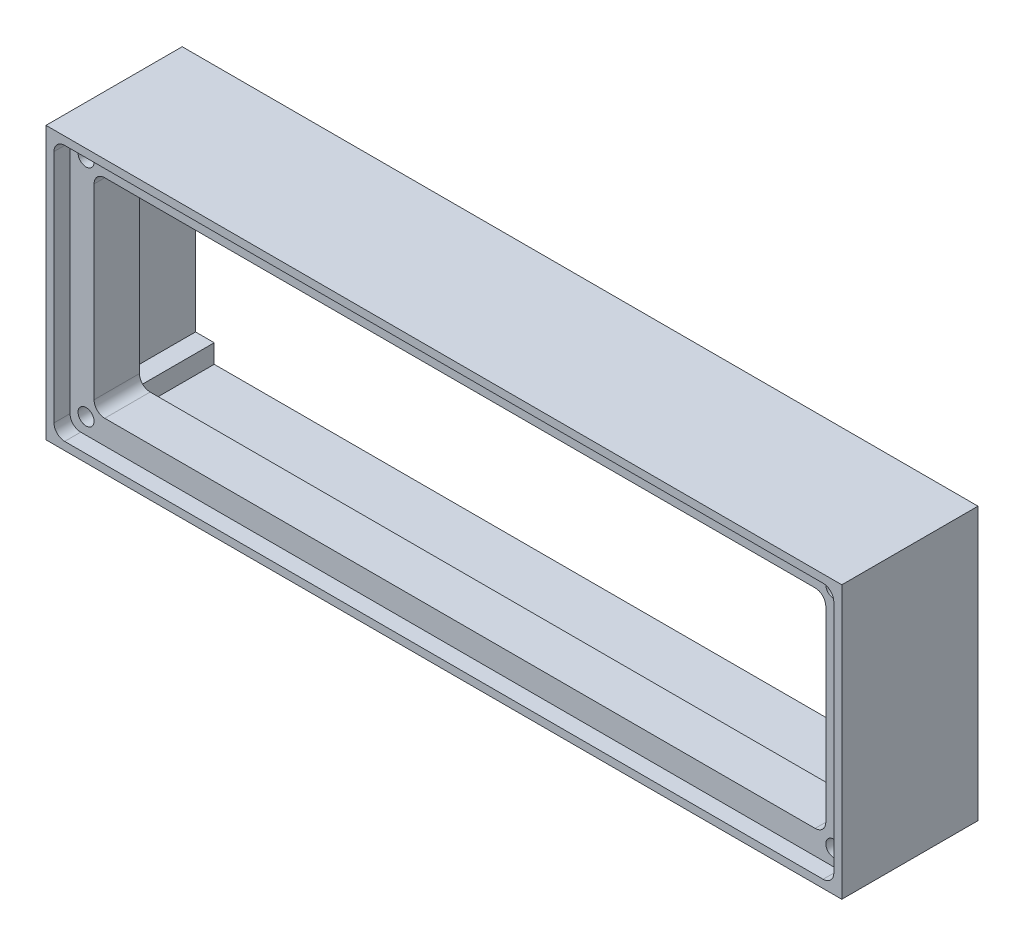
from build123d import *

# Parameters (mm, degrees)
SKETCH1_W           = 149
SKETCH1_H           = 51
SKETCH1_W_2         = 137
SKETCH1_H_2         = 39
EXTRUDE_THIN1_DEPTH = 25.5
SKETCH2_W           = 146
SKETCH2_H           = 48
CUT_EXTRUDE1_DEPTH  = 3
CUT_EXTRUDE2_DEPTH  = 8
CUT_EXTRUDE3_DEPTH  = 8
FILLET1_R           = 2
FILLET2_R           = 2
CUT_EXTRUDE7_DEPTH  = 14


with BuildPart() as part:
    # Sketch1 → Extrude-Thin1 (new body)
    with BuildSketch(Plane.XY):
        with Locations((74.5, 25.5)):
            Rectangle(SKETCH1_W, SKETCH1_H)
        with Locations((74.5, 25.5)):
            Rectangle(SKETCH1_W_2, SKETCH1_H_2, mode=Mode.SUBTRACT)
    extrude(amount=EXTRUDE_THIN1_DEPTH)

    # Sketch2 → Cut-Extrude1 (cut)
    with BuildSketch(Plane.XY.offset(25.5)):
        with Locations((74.5, 25.5)):
            Rectangle(SKETCH2_W, SKETCH2_H)
    extrude(amount=-CUT_EXTRUDE1_DEPTH, mode=Mode.SUBTRACT)

    # Sketch3 → Cut-Extrude2 (cut)
    with BuildSketch(Plane.XY.offset(22.5)):
        with BuildLine():
            ThreePointArc((4.5, 45), (5.560660172, 45.439339828), (6, 46.5))
            Line((6, 46.5), (4.5, 46.5))
            Line((4.5, 46.5), (4.5, 45))
        make_face()
        with BuildLine():
            Line((4.5, 46.5), (6, 46.5))
            ThreePointArc((6, 46.5), (3.439339828, 47.560660172), (4.5, 45))
            Line((4.5, 45), (4.5, 46.5))
        make_face()
        with BuildLine():
            ThreePointArc((4.5, 45), (5.560660172, 45.439339828), (6, 46.5))
            Line((6, 46.5), (4.5, 46.5))
            Line((4.5, 46.5), (4.5, 45))
        make_face()
        with BuildLine():
            Line((4.5, 46.5), (6, 46.5))
            ThreePointArc((6, 46.5), (3.439339828, 47.560660172), (4.5, 45))
            Line((4.5, 45), (4.5, 46.5))
        make_face()
        with BuildLine():
            ThreePointArc((6, 4.5), (5.560660172, 5.560660172), (4.5, 6))
            Line((4.5, 6), (4.5, 4.5))
            Line((4.5, 4.5), (6, 4.5))
        make_face()
        with BuildLine():
            Line((4.5, 4.5), (4.5, 6))
            ThreePointArc((4.5, 6), (3.439339828, 3.439339828), (6, 4.5))
            Line((6, 4.5), (4.5, 4.5))
        make_face()
        with BuildLine():
            ThreePointArc((6, 4.5), (5.560660172, 5.560660172), (4.5, 6))
            Line((4.5, 6), (4.5, 4.5))
            Line((4.5, 4.5), (6, 4.5))
        make_face()
        with BuildLine():
            Line((4.5, 4.5), (4.5, 6))
            ThreePointArc((4.5, 6), (3.439339828, 3.439339828), (6, 4.5))
            Line((6, 4.5), (4.5, 4.5))
        make_face()
        with BuildLine():
            ThreePointArc((146, 46.5), (144.5, 48), (143, 46.5))
            Line((143, 46.5), (144.5, 46.5))
            Line((144.5, 46.5), (144.5, 45))
            ThreePointArc((144.5, 45), (145.560660172, 45.439339828), (146, 46.5))
        make_face()
        with BuildLine():
            Line((144.5, 46.5), (143, 46.5))
            ThreePointArc((143, 46.5), (143.439339828, 45.439339828), (144.5, 45))
            Line((144.5, 45), (144.5, 46.5))
        make_face()
        with BuildLine():
            ThreePointArc((146, 46.5), (144.5, 48), (143, 46.5))
            Line((143, 46.5), (144.5, 46.5))
            Line((144.5, 46.5), (144.5, 45))
            ThreePointArc((144.5, 45), (145.560660172, 45.439339828), (146, 46.5))
        make_face()
        with BuildLine():
            Line((144.5, 46.5), (143, 46.5))
            ThreePointArc((143, 46.5), (143.439339828, 45.439339828), (144.5, 45))
            Line((144.5, 45), (144.5, 46.5))
        make_face()
        with BuildLine():
            ThreePointArc((146, 4.5), (145.560660172, 5.560660172), (144.5, 6))
            Line((144.5, 6), (144.5, 4.5))
            Line((144.5, 4.5), (143, 4.5))
            ThreePointArc((143, 4.5), (144.5, 3), (146, 4.5))
        make_face()
        with BuildLine():
            Line((144.5, 4.5), (144.5, 6))
            ThreePointArc((144.5, 6), (143.439339828, 5.560660172), (143, 4.5))
            Line((143, 4.5), (144.5, 4.5))
        make_face()
        with BuildLine():
            ThreePointArc((146, 4.5), (145.560660172, 5.560660172), (144.5, 6))
            Line((144.5, 6), (144.5, 4.5))
            Line((144.5, 4.5), (143, 4.5))
            ThreePointArc((143, 4.5), (144.5, 3), (146, 4.5))
        make_face()
        with BuildLine():
            Line((144.5, 4.5), (144.5, 6))
            ThreePointArc((144.5, 6), (143.439339828, 5.560660172), (143, 4.5))
            Line((143, 4.5), (144.5, 4.5))
        make_face()
    extrude(amount=-CUT_EXTRUDE2_DEPTH, mode=Mode.SUBTRACT)

    # Sketch4 → Cut-Extrude3 (cut)
    with BuildSketch(Plane(origin=(0, 0, 0), x_dir=(-1, 0, 0), z_dir=(0, 0, -1))):
        with BuildLine():
            ThreePointArc((-146, 46.5), (-144.939339828, 46.939339828), (-144.5, 48))
            Line((-144.5, 48), (-146, 48))
            Line((-146, 48), (-146, 46.5))
        make_face()
        with BuildLine():
            Line((-146, 48), (-144.5, 48))
            ThreePointArc((-144.5, 48), (-147.060660172, 49.060660172), (-146, 46.5))
            Line((-146, 46.5), (-146, 48))
        make_face()
        with BuildLine():
            ThreePointArc((-146, 4.5), (-147.060660172, 1.939339828), (-144.5, 3))
            Line((-144.5, 3), (-146, 3))
            Line((-146, 3), (-146, 4.5))
        make_face()
        with BuildLine():
            Line((-146, 3), (-144.5, 3))
            ThreePointArc((-144.5, 3), (-144.939339828, 4.060660172), (-146, 4.5))
            Line((-146, 4.5), (-146, 3))
        make_face()
        with BuildLine():
            ThreePointArc((-146, 4.5), (-147.060660172, 1.939339828), (-144.5, 3))
            Line((-144.5, 3), (-146, 3))
            Line((-146, 3), (-146, 4.5))
        make_face()
        with BuildLine():
            Line((-146, 3), (-144.5, 3))
            ThreePointArc((-144.5, 3), (-144.939339828, 4.060660172), (-146, 4.5))
            Line((-146, 4.5), (-146, 3))
        make_face()
        with BuildLine():
            ThreePointArc((-146, 46.5), (-144.939339828, 46.939339828), (-144.5, 48))
            Line((-144.5, 48), (-146, 48))
            Line((-146, 48), (-146, 46.5))
        make_face()
        with BuildLine():
            Line((-146, 48), (-144.5, 48))
            ThreePointArc((-144.5, 48), (-147.060660172, 49.060660172), (-146, 46.5))
            Line((-146, 46.5), (-146, 48))
        make_face()
        with BuildLine():
            ThreePointArc((-4.5, 48), (-4.060660172, 46.939339828), (-3, 46.5))
            Line((-3, 46.5), (-3, 48))
            Line((-3, 48), (-4.5, 48))
        make_face()
        with BuildLine():
            Line((-3, 48), (-3, 46.5))
            ThreePointArc((-3, 46.5), (-1.939339828, 46.939339828), (-1.5, 48))
            ThreePointArc((-1.5, 48), (-3, 49.5), (-4.5, 48))
            Line((-4.5, 48), (-3, 48))
        make_face()
        with BuildLine():
            ThreePointArc((-4.5, 48), (-4.060660172, 46.939339828), (-3, 46.5))
            Line((-3, 46.5), (-3, 48))
            Line((-3, 48), (-4.5, 48))
        make_face()
        with BuildLine():
            Line((-3, 48), (-3, 46.5))
            ThreePointArc((-3, 46.5), (-1.939339828, 46.939339828), (-1.5, 48))
            ThreePointArc((-1.5, 48), (-3, 49.5), (-4.5, 48))
            Line((-4.5, 48), (-3, 48))
        make_face()
        with BuildLine():
            Line((-4.5, 3), (-3, 3))
            Line((-3, 3), (-3, 4.5))
            ThreePointArc((-3, 4.5), (-4.060660172, 4.060660172), (-4.5, 3))
        make_face()
        with BuildLine():
            Line((-3, 4.5), (-3, 3))
            Line((-3, 3), (-4.5, 3))
            ThreePointArc((-4.5, 3), (-3, 1.5), (-1.5, 3))
            ThreePointArc((-1.5, 3), (-1.939339828, 4.060660172), (-3, 4.5))
        make_face()
        with BuildLine():
            Line((-4.5, 3), (-3, 3))
            Line((-3, 3), (-3, 4.5))
            ThreePointArc((-3, 4.5), (-4.060660172, 4.060660172), (-4.5, 3))
        make_face()
        with BuildLine():
            Line((-3, 4.5), (-3, 3))
            Line((-3, 3), (-4.5, 3))
            ThreePointArc((-4.5, 3), (-3, 1.5), (-1.5, 3))
            ThreePointArc((-1.5, 3), (-1.939339828, 4.060660172), (-3, 4.5))
        make_face()
    extrude(amount=-CUT_EXTRUDE3_DEPTH, mode=Mode.SUBTRACT)

    # Fillet1
    fillet1_edges = [part.edges().sort_by_distance(p)[0] for p in [
        (1.5, 49.5, 24),
        (147.5, 49.5, 24),
        (147.5, 1.5, 24),
        (1.5, 1.5, 24),
    ]]
    fillet(fillet1_edges, radius=FILLET1_R)

    # Fillet2
    fillet2_edges = [part.edges().sort_by_distance(p)[0] for p in [
        (143, 45, 11.25),
        (6, 45, 11.25),
        (143, 6, 11.25),
        (6, 6, 11.25),
    ]]
    fillet(fillet2_edges, radius=FILLET2_R)

    # Sketch6 → Cut-Extrude7 (cut)
    with BuildSketch(Plane(origin=(0, 0, 0), x_dir=(-1, 0, 0), z_dir=(0, 0, -1))):
        Polygon((-143, 45), (-146.5, 45), (-146.5, 6), (-143, 6), (-143, 2.5), (-6, 2.5), (-6, 6), (-2.5, 6), (-2.5, 45), (-6, 45), (-6, 48.5), (-143, 48.5), align=None)
    extrude(amount=-CUT_EXTRUDE7_DEPTH, mode=Mode.SUBTRACT)


solid = part.part
